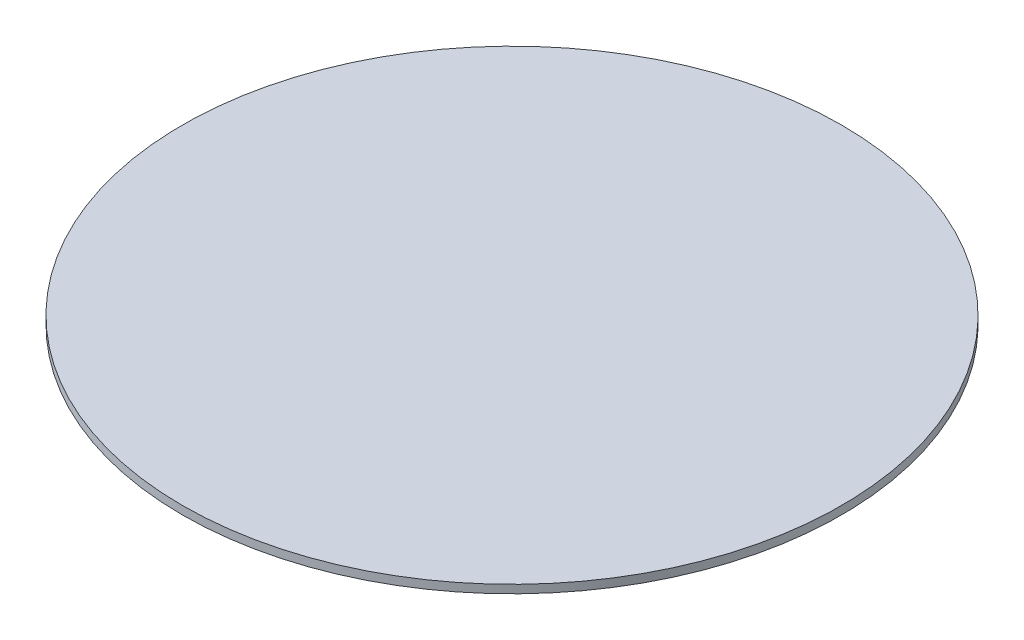
from build123d import *

# Parameters (mm, degrees)
SKETCH1_R           = 127
BOSS_EXTRUDE1_DEPTH = 3.175


with BuildPart() as part:
    # Sketch1 → Boss-Extrude1 (new body)
    with BuildSketch(Plane(origin=(0, 0, 0), x_dir=(1, 0, 0), z_dir=(0, 1, 0))):
        Circle(SKETCH1_R)
    extrude(amount=BOSS_EXTRUDE1_DEPTH)


solid = part.part
